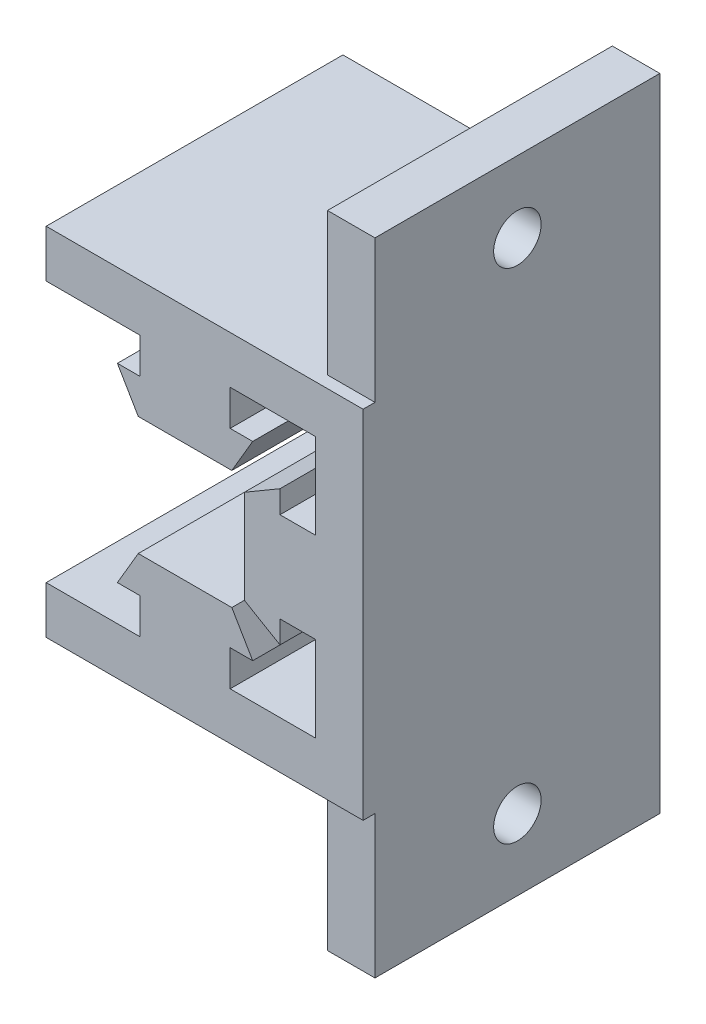
from build123d import *

# Parameters (mm, degrees)
RESSALTO_EXTRUS_O3_DEPTH = 25
ESBO_O6_W                = 4
ESBO_O6_H                = 16
RESSALTO_EXTRUS_O6_DEPTH = 24
ESBO_O7_R                = 2
CORTE_EXTRUS_O3_DEPTH    = 43


with BuildPart() as part:
    # Esboço1 → Ressalto-extrusão3 (new body)
    with BuildSketch(Plane.XY):
        Polygon((-3.8, 33.5), (-5.7, 33.5), (-3.940587347, 30.5), (3.940587347, 30.5), (5.7, 33.5), (3.8, 33.5), (3.8, 36.5), (11, 36.5), (11, 29.3), (8, 29.3), (8, 31.2), (5, 29.440587347), (5, 21.559412653), (8, 19.8), (8, 21.7), (11, 21.7), (11, 14.5), (3.8, 14.5), (3.8, 17.5), (5.7, 17.5), (3.940587347, 20.5), (-3.940587347, 20.5), (-5.7, 17.5), (-3.8, 17.5), (-3.8, 14.5), (-11.2, 14.5), (-11.7, 14.5), (-11.7, 10.5), (11.7, 10.5), (15, 10.5), (15, 37.2), (15, 40.5), (-11.7, 40.5), (-11.7, 36.5), (-3.8, 36.5), align=None)
    extrude(amount=RESSALTO_EXTRUS_O3_DEPTH)

    # Esboço6 → Ressalto-extrusão6 (add)
    with BuildSketch(Plane.XY):
        with Locations((13, 44.5)):
            Rectangle(ESBO_O6_W, ESBO_O6_H)
        with Locations((13, 6.5)):
            Rectangle(ESBO_O6_W, ESBO_O6_H)
    extrude(amount=RESSALTO_EXTRUS_O6_DEPTH)

    # Esboço7 → Corte-extrusão3 (cut)
    with BuildSketch(Plane(origin=(0, 0, 0), x_dir=(0, 0, -1), z_dir=(1, 0, 0))):
        with Locations((-12, 46.5)):
            Circle(ESBO_O7_R)
        with Locations((-12, 4.5)):
            Circle(ESBO_O7_R)
    extrude(amount=CORTE_EXTRUS_O3_DEPTH, mode=Mode.SUBTRACT)


solid = part.part
